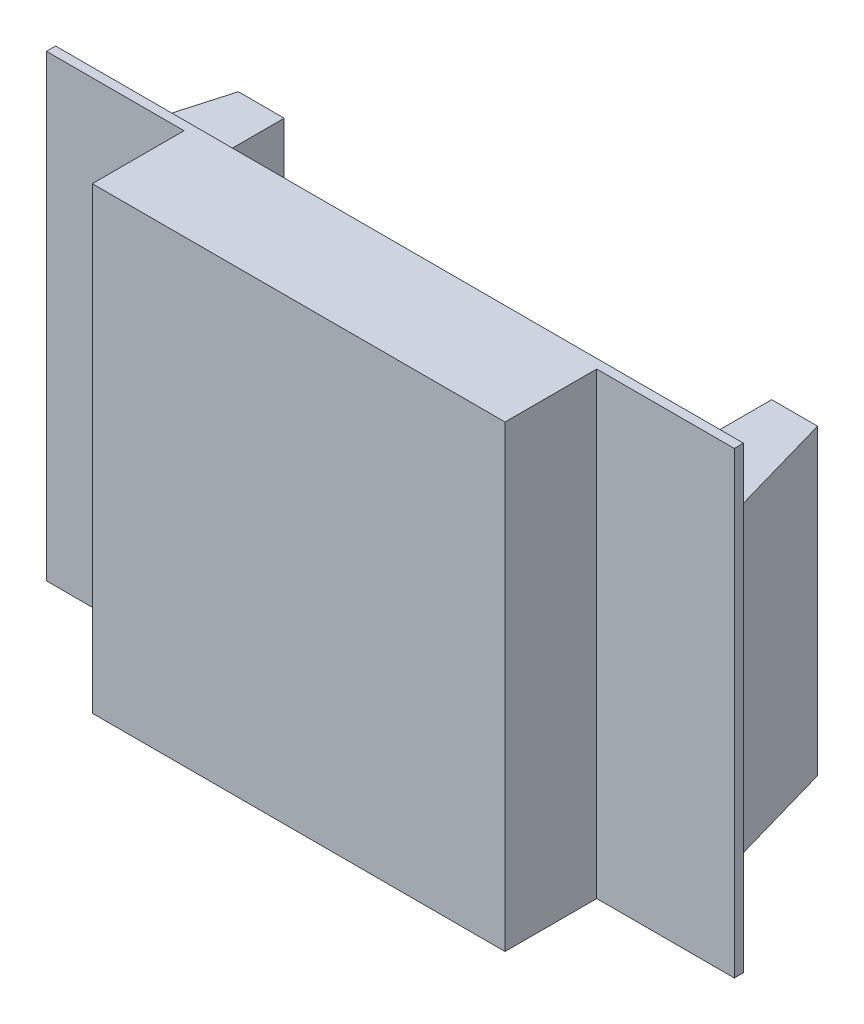
from build123d import *

# Parameters (mm, degrees)
SKETCH1_W                       = 75
SKETCH1_H                       = 50
BOSS_EXTRUDE1_DEPTH             = 1
BOSS_EXTRUDE2_REACH             = 43.356
SKETCH2_W                       = 45
SKETCH2_H                       = 10
BOSS_EXTRUDE2_DIRECTION_2_REACH = 10.644
BOSS_EXTRUDE5_DEPTH             = 33


with BuildPart() as part:
    # Sketch1 → Boss-Extrude1 (new body)
    with BuildSketch(Plane.XY):
        with Locations((-4.920212766, 16.356382979)):
            Rectangle(SKETCH1_W, SKETCH1_H)
    extrude(amount=BOSS_EXTRUDE1_DEPTH)

    # Boss-Extrude2: up to this face of the body (flat: up to its plane)
    boss_extrude2_end = Plane(part.part.faces().sort_by_distance((-4.920212766, 41.356382979, 0.5))[0])
    # Sketch2 → Boss-Extrude2 (add, up to the picked face)
    with BuildSketch(Plane(origin=(0, 0, 0), x_dir=(1, 0, 0), z_dir=(0, 1, 0)), mode=Mode.PRIVATE) as boss_extrude2_sk1:
        with Locations((-4.920212766, -6)):
            Rectangle(SKETCH2_W, SKETCH2_H)
    boss_extrude2_tool1 = split(extrude(boss_extrude2_sk1.sketch, amount=BOSS_EXTRUDE2_REACH, mode=Mode.PRIVATE), bisect_by=boss_extrude2_end, keep=Keep.BOTH, mode=Mode.PRIVATE)
    add(boss_extrude2_tool1.solids().sort_by_distance((-4.920213, 0, 6))[0])

    # Boss-Extrude2 direction 2: up to this face of the body (flat: up to its plane)
    boss_extrude2_direction_2_end = Plane(part.part.faces().sort_by_distance((-4.920212766, -8.643617021, 0.5))[0])
    # Sketch2 → Boss-Extrude2 direction 2 (add, up to the picked face)
    with BuildSketch(Plane(origin=(0, 0, 0), x_dir=(1, 0, 0), z_dir=(0, 1, 0)), mode=Mode.PRIVATE) as boss_extrude2_direction_2_sk1:
        with Locations((-4.920212766, -6)):
            Rectangle(SKETCH2_W, SKETCH2_H)
    boss_extrude2_direction_2_tool1 = split(extrude(boss_extrude2_direction_2_sk1.sketch, amount=-BOSS_EXTRUDE2_DIRECTION_2_REACH, mode=Mode.PRIVATE), bisect_by=boss_extrude2_direction_2_end, keep=Keep.BOTH, mode=Mode.PRIVATE)
    add(boss_extrude2_direction_2_tool1.solids().sort_by_distance((-4.920213, 0, 6))[0])

    # Sketch4 → Boss-Extrude5 (add)
    with BuildSketch(Plane(origin=(0, 0, 0), x_dir=(1, 0, 0), z_dir=(0, 1, 0))):
        Polygon((-40.49649997, 0), (-36.49649997, 14), (-31.49649997, 14), (-31.49649997, 0), align=None)
        Polygon((21.656074438, 0), (30.656074438, 0), (26.656074438, 14), (21.656074438, 14), align=None)
    extrude(amount=BOSS_EXTRUDE5_DEPTH)


solid = part.part
